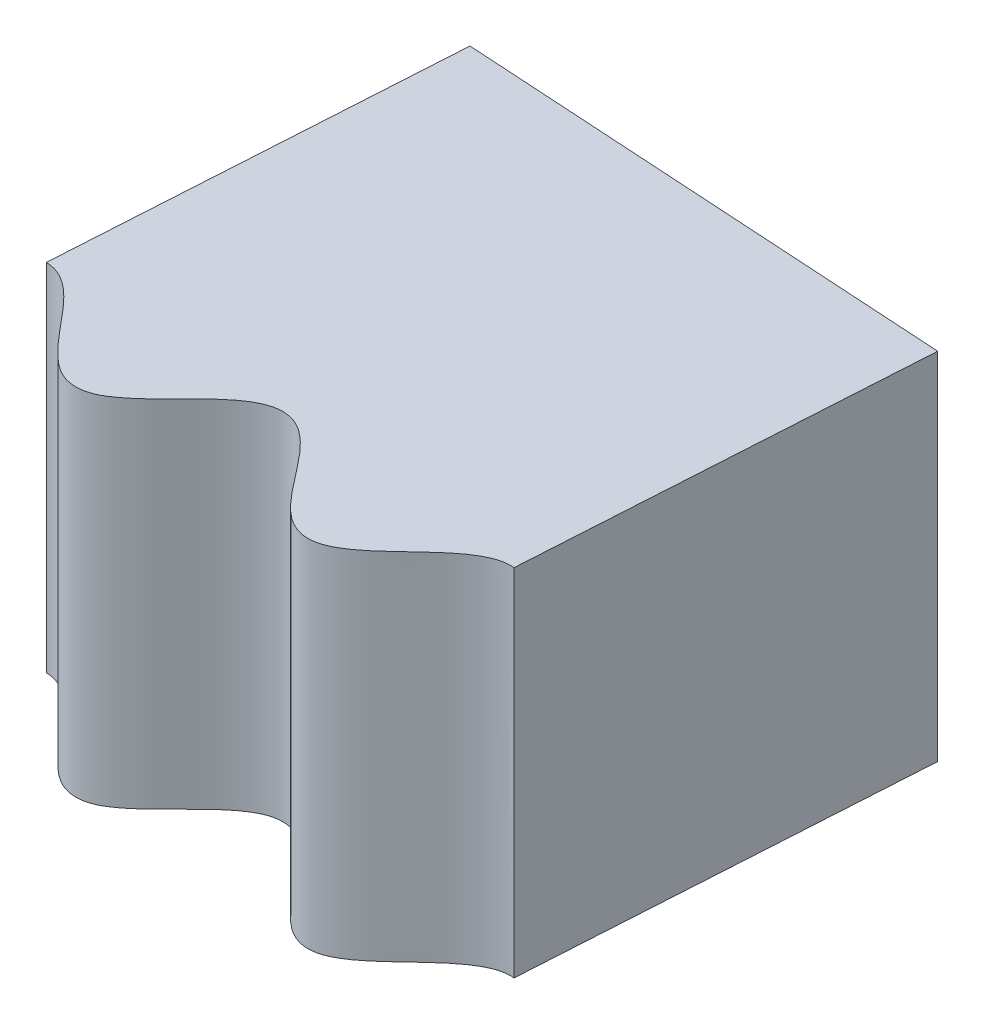
from build123d import *

# Parameters (mm, degrees)
BOSS_EXTRUDE1_DEPTH     = 4
CUT_EXTRUDE2_DEPTH      = 121.274685761
CUT_EXTRUDE2_DEPTH_BACK = 121.274685761
CUT_EXTRUDE1_DEPTH      = 121.251093253
CUT_EXTRUDE1_DEPTH_BACK = 121.251093253
CUT_EXTRUDE3_DEPTH      = 86.435194315
CUT_EXTRUDE3_DEPTH_BACK = 86.435194315


with BuildPart() as part:
    # Sketch1 → Boss-Extrude1 (new body)
    with BuildSketch(Plane(origin=(0, 0, 0), x_dir=(1, 0, 0), z_dir=(0, 1, 0))):
        with BuildLine():
            Line((0, 80), (0, 85))
            ThreePointArc((0, 85), (60.104076401, 60.104076401), (85, 0))
            Line((85, 0), (80, 0))
            add(Edge.make_bspline(
                [(80, 0), (80.032090717, 0.028525082), (80.09667822, 0.086017331), (80.241929685, 0.217881601), (80.358059175, 0.349965911), (80.491818845, 0.541955952), (80.520745314, 0.783221767), (80.395327209, 1.015001531), (80.21322013, 1.199882887), (80.019631559, 1.371789898), (79.826748629, 1.530214422), (79.652000677, 1.70136719), (79.499388097, 1.886384289), (79.436617102, 2.157129349), (79.580228142, 2.421089692), (79.756663775, 2.606493625), (79.935468278, 2.777108248), (80.081231654, 2.915952271), (80.195849331, 3.032747038), (80.318945031, 3.184834192), (80.449207906, 3.391122788), (80.430985375, 3.64769414), (80.283129745, 3.837080355), (80.117832534, 4.004725139), (79.930022356, 4.155872665), (79.708375258, 4.329496591), (79.496329517, 4.518081178), (79.348442966, 4.734680192), (79.342274426, 4.961075155), (79.417139165, 5.131209739), (79.541145524, 5.302751999), (79.700661546, 5.478726151), (79.895818296, 5.665940565), (80.087266659, 5.883785833), (80.264900479, 6.127148528), (80.26976254, 6.439577112), (80.0755926, 6.668708746), (79.870536592, 6.84659362), (79.650975963, 7.00393118), (79.449988691, 7.155400956), (79.27401932, 7.316136075), (79.133629081, 7.503746818), (79.112665659, 7.768606839), (79.258587358, 8.017453494), (79.445412966, 8.24075344), (79.677556155, 8.482920187), (79.871420236, 8.718646235), (80.039596562, 9.019993428), (79.92941115, 9.346326353), (79.684651627, 9.547767873), (79.43513913, 9.732924875), (79.168139401, 9.907991918), (78.948472427, 10.088325954), (78.798706362, 10.315149052), (78.818197293, 10.555217344), (78.907498739, 10.733000974), (79.031571912, 10.909532487), (79.179071405, 11.085986895), (79.343006349, 11.272289095), (79.500190837, 11.48122682), (79.627415603, 11.704481342), (79.633691009, 11.961120851), (79.497215431, 12.15943856), (79.333489111, 12.302792108), (79.151724532, 12.428199271), (78.96735588, 12.545156022), (78.781957065, 12.663685776), (78.608128462, 12.796358014), (78.448949239, 12.957441509), (78.373672933, 13.186175672), (78.44663846, 13.417225876), (78.569172307, 13.615068933), (78.712974029, 13.803259394), (78.859737418, 13.984594552), (79.002279528, 14.174046118), (79.121513223, 14.373582722), (79.192049351, 14.616633976), (79.096415003, 14.86130363), (78.903467998, 15.028975991), (78.691277914, 15.172659445), (78.479735827, 15.293184025), (78.285251138, 15.410267973), (78.111351638, 15.534657737), (77.967813395, 15.671478127), (77.865884414, 15.886642463), (77.923041339, 16.149590225), (78.071503052, 16.388213081), (78.255696078, 16.639452654), (78.420932264, 16.860272656), (78.544873375, 17.07058574), (78.610556053, 17.271422439), (78.602249155, 17.452728269), (78.491816209, 17.645978489), (78.286096374, 17.809888636), (78.026536396, 17.955157584), (77.723668771, 18.11800232), (77.462777072, 18.277975), (77.276991592, 18.510420725), (77.289695754, 18.771670067), (77.375412583, 18.967131426), (77.491230255, 19.162148753), (77.62406371, 19.35464712), (77.766439251, 19.559540843), (77.890938798, 19.77975678), (77.982928534, 20.031857992), (77.908617702, 20.297849989), (77.703954888, 20.469361632), (77.487293574, 20.600952596), (77.263484027, 20.710373317), (77.05385777, 20.814877214), (76.859115823, 20.930266104), (76.690132494, 21.062003172), (76.560195053, 21.288945194), (76.617887744, 21.580128607), (76.768630472, 21.845533697), (76.955776817, 22.134761377), (77.110836158, 22.388081211), (77.209207274, 22.632836471), (77.205193549, 22.855709333), (77.119274234, 23.015399798), (76.962130826, 23.156168852), (76.751178763, 23.278597763), (76.499083101, 23.390850954), (76.21708721, 23.52206724), (75.971563576, 23.660183858), (75.799525977, 23.867867226), (75.792450997, 24.105862415), (75.853791353, 24.293834195), (75.947079263, 24.486611265), (76.060800958, 24.682820779), (76.187126301, 24.891290148), (76.302107973, 25.119836012), (76.385056234, 25.358438422), (76.345683614, 25.608740652), (76.178082821, 25.779240722), (75.991835141, 25.892009555), (75.791119726, 25.983935286), (75.589210335, 26.067106475), (75.386060909, 26.151638253), (75.19182829, 26.252111207), (75.007098158, 26.383105764), (74.893244889, 26.595293611), (74.924981219, 26.835503821), (75.011297963, 27.051619068), (75.120236333, 27.26192135), (75.233281408, 27.46598684), (75.340760126, 27.677312377), (75.423533198, 27.89452229), (75.450792328, 28.146129517), (75.314124435, 28.370475361), (75.094992733, 28.502095505), (74.861075921, 28.606749663), (74.63181876, 28.688709306), (74.419957316, 28.770242574), (74.227099685, 28.862545246), (74.061983498, 28.972361874), (73.924240153, 29.166557598), (73.934868336, 29.435435788), (74.039638158, 29.696213533), (74.177405584, 29.975620996), (74.30178647, 30.221779208), (74.387324153, 30.450419312), (74.417134037, 30.659610527), (74.377469912, 30.836719437), (74.235157143, 31.007857271), (74.004099956, 31.133554381), (73.723257589, 31.23154425), (73.396713512, 31.339322597), (73.11200638, 31.451561565), (72.888679623, 31.648214607), (72.855825307, 31.907701039), (72.906298397, 32.115077472), (72.986492135, 32.327243575), (73.08388056, 32.539883747), (73.188513675, 32.766387927), (73.272881698, 33.004877409), (73.319696988, 33.269122487), (73.200326078, 33.518169527), (72.968989868, 33.651536198), (72.732769595, 33.743505157), (72.493359509, 33.812399412), (72.268771035, 33.878914442), (72.056950585, 33.958733732), (71.867658591, 34.059125771), (71.700287123, 34.260056633), (71.706539863, 34.556834546), (71.808905361, 34.844383737), (71.942984673, 35.16171502), (72.051699786, 35.438112129), (72.106075118, 35.696230972), (72.063420905, 35.915020918), (71.951076939, 36.057365594), (71.771876603, 36.168708383), (71.542869818, 36.252645883), (71.275111493, 36.319417743), (70.974614286, 36.399672486), (70.708837008, 36.493056071), (70.503349209, 36.667710246), (70.455054282, 36.900861195), (70.482821783, 37.096628904), (70.541217053, 37.302676532), (70.619139636, 37.515652748), (70.707345486, 37.742891163), (70.780893757, 37.987931262), (70.821148972, 38.237312577), (70.738909987, 38.476975175), (70.544248397, 38.615781384), (70.341248141, 38.694495455), (70.127619294, 38.750170714), (69.914334866, 38.797017253), (69.699592885, 38.844988062), (69.490864268, 38.910206862), (69.286193433, 39.007132581), (69.137224181, 39.196327638), (69.126765553, 39.438396934), (69.174244689, 39.666223619), (69.245005567, 39.892234757), (69.320905484, 40.112856767), (69.390040016, 40.339584176), (69.433863759, 40.567956834), (69.416975097, 40.820330666), (69.243496538, 41.017774742), (69.00470764, 41.108899633), (68.756436896, 41.172245697), (68.466910477, 41.219591467), (68.197666367, 41.278141747), (67.943151909, 41.357183881), (67.736316654, 41.559824915), (67.700319728, 41.827233163), (67.75804595, 42.101670586), (67.845317695, 42.401149899), (67.924993563, 42.664927635), (67.969563917, 42.905066899), (67.962580745, 43.116207209), (67.892770749, 43.283758824), (67.722899219, 43.427574017), (67.473527204, 43.511245532), (67.179934405, 43.558974547), (66.839636545, 43.608414404), (66.539764229, 43.669507867), (66.285682076, 43.824393739), (66.208267435, 44.074232523), (66.221963252, 44.287223227), (66.26409637, 44.510091413), (66.323080689, 44.736412497), (66.386792142, 44.977644882), (66.428465168, 45.227161545), (66.428683549, 45.495521527), (66.267879588, 45.720056447), (66.016899014, 45.811225864), (65.768297217, 45.86077839), (65.520560946, 45.88705286), (65.287834261, 45.913557999), (65.065371366, 45.955382419), (64.861522248, 46.021379067), (64.66180225, 46.190193588), (64.616425054, 46.483548555), (64.667302997, 46.784504809), (64.744241344, 47.120297745), (64.803308976, 47.411373942), (64.812036358, 47.675013557), (64.732037682, 47.883072766), (64.596682581, 48.003746581), (64.400870228, 48.082280012), (64.160766977, 48.125175701), (63.885481691, 48.144437402), (63.57561362, 48.171292103), (63.297658207, 48.217105241), (63.06496385, 48.353423445), (62.976916395, 48.574645982), (62.97026734, 48.772261314), (62.991995659, 48.985318849), (63.031751491, 49.208590592), (63.07915776, 49.447693531), (63.1090379, 49.701782441), (63.105376938, 49.954365341), (62.982770373, 50.176106271), (62.766962686, 50.279001081), (62.553377903, 50.321268662), (62.333326657, 50.339001879), (62.11514767, 50.348100153), (61.895338083, 50.358052845), (61.67845535, 50.386035069), (61.460063031, 50.445948262), (61.280503436, 50.606399505), (61.228169101, 50.842977732), (61.23536454, 51.075581698), (61.265805507, 51.310460321), (61.302238619, 51.540882841), (61.330957991, 51.77622379), (61.334449064, 52.008644375), (61.274009538, 52.254401043), (61.068852913, 52.418473933), (60.817919761, 52.467209091), (60.562315958, 52.485547277), (60.318852992, 52.484154182), (60.091882052, 52.488308333), (59.879086348, 52.509085605), (59.686367417, 52.5558024), (59.490513811, 52.691182513), (59.408536076, 52.947467163), (59.417803094, 53.228379739), (59.451686341, 53.538003137), (59.48439634, 53.811944809), (59.486542639, 54.055914862), (59.443062665, 54.262911016), (59.345103597, 54.415343831), (59.190928965, 54.506209058), (59.021409133, 54.546859543), (58.807638529, 54.565859484), (58.593895644, 54.563222757), (58.381584392, 54.55475325), (58.124257423, 54.557523545), (57.903842493, 54.575977162), (57.668244673, 54.669734184), (57.549220989, 54.901168507), (57.525372989, 55.113986964), (57.528372044, 55.340380655), (57.547048857, 55.573723864), (57.567961543, 55.822239621), (57.565644354, 56.075258871), (57.519272798, 56.339553105), (57.321914222, 56.532768248), (57.05892014, 56.578960596), (56.805487151, 56.584597543), (56.556953981, 56.567450078), (56.323159349, 56.553141981), (56.096813892, 56.555699812), (55.884601315, 56.585296164), (55.658601271, 56.716864817), (55.562972842, 56.997883513), (55.560817371, 57.303102343), (55.578276993, 57.647154089), (55.58590242, 57.944065138), (55.548716667, 58.205214985), (55.433804252, 58.396221677), (55.279550709, 58.491558022), (55.073075999, 58.534895893), (54.829171697, 58.535446409), (54.554723854, 58.506612692), (54.244900106, 58.479251385), (53.963212093, 58.476102067), (53.710381478, 58.569942341), (53.585256771, 58.77251473), (53.544393188, 58.965973245), (53.528794352, 59.17956704), (53.529175472, 59.406350311), (53.534341744, 59.650052751), (53.519645861, 59.905470112), (53.472179957, 60.153579991), (53.312931153, 60.350661771), (53.082534573, 60.414518766), (52.864854935, 60.4190556), (52.645067421, 60.398307911), (52.428623164, 60.369381578), (52.210424712, 60.341013532), (51.991977853, 60.330909353), (51.766499587, 60.351988902), (51.56180584, 60.478822333), (51.469185203, 60.702718643), (51.435880072, 60.933038307), (51.425072328, 61.169634614), (51.420939489, 61.402883042), (51.408356022, 61.6396357), (51.371434647, 61.869131511), (51.269238134, 62.100659372), (51.038707343, 62.226614549), (50.783123655, 62.231035232), (50.528218662, 62.204709672), (50.288696339, 62.161060868), (50.064452267, 62.125738764), (49.851281413, 62.109248902), (49.653378132, 62.12179049), (49.436991297, 62.221104565), (49.311755967, 62.459259785), (49.272101514, 62.73751516), (49.251705822, 63.048316025), (49.236347146, 63.323779964), (49.196099437, 63.564409949), (49.117329558, 63.760721738), (48.994401411, 63.893806335), (48.826762435, 63.956568769), (48.652821836, 63.967053399), (48.481411531, 63.95253118), (48.313051571, 63.924683497), (48.145760164, 63.89112429), (47.979054672, 63.856686781), (47.767363224, 63.821917449), (47.547153873, 63.801706918), (47.298824952, 63.853181073), (47.141436232, 64.06040471), (47.08098684, 64.265863314), (47.044632196, 64.489329977), (47.022503129, 64.72237584), (46.99994512, 64.970745182), (46.953726148, 65.219519286), (46.862165177, 65.471745417), (46.634253291, 65.62775453), (46.367233583, 65.627576472), (46.116671871, 65.589119738), (45.874892187, 65.529075371), (45.6471339, 65.474386676), (45.42378312, 65.437601152), (45.209654949, 65.429897551), (44.964242071, 65.520222877), (44.821267356, 65.780366575), (44.766145395, 66.080574134), (44.723593139, 66.422430823), (44.679549023, 66.716155218), (44.597573383, 66.966880449), (44.451249003, 67.135030872), (44.282763127, 67.202133233), (44.071948553, 67.208958193), (43.831535787, 67.167148153), (43.566501769, 67.091092419), (43.265745622, 67.0103509), (42.989451242, 66.958328371), (42.723403015, 67.0068481), (42.531623083, 67.223524481), (42.459146095, 67.478843201), (42.406452888, 67.749929216), (42.363518024, 68.039968415), (42.303789017, 68.288963767), (42.214408297, 68.525056842), (42.023119942, 68.691493925), (41.785273045, 68.714371273), (41.570029687, 68.681040452), (41.35723005, 68.622441743), (41.14907401, 68.556369978), (40.939127385, 68.490543019), (40.725749124, 68.442659499), (40.500037844, 68.424264891), (40.27642853, 68.513626752), (40.146336363, 68.718038162), (40.0735423, 68.939075383), (40.02181441, 69.17020051), (39.977241101, 69.399187719), (39.923737184, 69.63015846), (39.847525174, 69.849756412), (39.706676881, 70.060020561), (39.457776467, 70.14403102), (39.205308049, 70.104002757), (38.958846977, 70.033813665), (38.730543162, 69.949234732), (38.515839305, 69.875510927), (38.308770774, 69.822252381), (38.111695669, 69.800242159), (37.88135154, 69.860464998), (37.716661631, 70.073269306), (37.629295268, 70.340381392), (37.555231584, 70.642975121), (37.492285422, 70.911493744), (37.410844062, 71.141624788), (37.299214237, 71.32103598), (37.154986342, 71.431213668), (36.935963157, 71.470835971), (36.678166538, 71.418604846), (36.400042129, 71.313147447), (36.080616268, 71.185811964), (35.790372133, 71.088785785), (35.492887773, 71.095879082), (35.300925244, 71.273538875), (35.206290872, 71.464841915), (35.131345097, 71.678918121), (35.069266491, 71.904410015), (35.003826028, 72.145179155), (34.915157597, 72.382103417), (34.781166731, 72.614619178), (34.529638952, 72.728670137), (34.266698699, 72.682134886), (34.026626946, 72.600747729), (33.798943844, 72.499633959), (33.584143983, 72.406224728), (33.370573385, 72.331214312), (33.161036326, 72.286444492), (32.90366684, 72.332782216), (32.717690853, 72.564146358), (32.611275751, 72.850221323), (32.510007216, 73.179495283), (32.415627492, 73.461109179), (32.291359286, 73.693790414), (32.118058874, 73.833977272), (31.940480493, 73.870802981), (31.731683486, 73.840916569), (31.502183458, 73.757994769), (31.254382661, 73.637071233), (30.97221659, 73.505331565), (30.709152931, 73.406119968), (30.438721781, 73.407705635), (30.212229022, 73.587784936), (30.096519567, 73.826646036), (29.997549177, 74.084450185), (29.904908502, 74.362649209), (29.802837921, 74.597452886), (29.673836044, 74.814497117), (29.456524224, 74.945097584), (29.218370619, 74.926496163), (29.01206448, 74.855903152), (28.763118785, 74.738529977), (28.522990551, 74.607093087), (28.275755591, 74.488415411), (28.003061301, 74.417695808), (27.76723664, 74.466562248), (27.603684062, 74.645469155), (27.493577147, 74.850390665), (27.402520796, 75.069087435), (27.318851046, 75.28682196), (27.226057413, 75.505009403), (27.112868166, 75.708029671), (26.937648658, 75.890644537), (26.677940829, 75.930155929), (26.436259135, 75.846896167), (26.205730352, 75.734975187), (25.995582087, 75.612037062), (25.796942005, 75.502150149), (25.602267587, 75.413743734), (25.412008521, 75.357846132), (25.174706255, 75.377155227), (24.975565273, 75.558128448), (24.843142676, 75.806011498), (24.717659335, 76.09114712), (24.609041698, 76.344655858), (24.488875778, 76.557148549), (24.347787435, 76.714449767), (24.186618531, 76.797908697), (23.964042459, 76.798896071), (23.719232189, 76.702692541), (23.463645601, 76.55054148), (23.17118411, 76.369672791), (22.902197856, 76.223720292), (22.608001214, 76.179048209), (22.388104727, 76.320675007), (22.26168864, 76.492638639), (22.150707517, 76.690448348), (22.050415767, 76.901734677), (21.94416037, 77.127482375), (21.815697545, 77.345410114), (21.643366363, 77.551126169), (21.375855115, 77.619767097), (21.124990277, 77.528279725), (20.902698485, 77.406440999), (20.696032623, 77.267326619), (20.500716397, 77.13803688), (20.303415839, 77.027079896), (20.104836316, 76.946604501), (19.84333039, 76.947546508), (19.620003833, 77.143101318), (19.46552902, 77.406351373), (19.308621159, 77.713037825), (19.166773535, 77.973984506), (19.003988569, 78.181551843), (18.808977788, 78.289515647), (18.627702504, 78.294945729), (18.427267314, 78.229256138), (18.215653126, 78.107741846), (17.992615131, 77.945625253), (17.737612151, 77.766889383), (17.495772932, 77.623504507), (17.229174892, 77.578106208), (16.974852624, 77.716119645), (16.819423261, 77.931259172), (16.677189234, 78.167960668), (16.537647223, 78.425846342), (16.396354096, 78.639358448), (16.231622708, 78.830704356), (15.994933815, 78.921584896), (15.763628392, 78.861911154), (15.572714877, 78.756565877), (15.347932812, 78.597747007), (15.134276544, 78.426608894), (14.911405636, 78.266802645), (14.655134737, 78.1498041), (14.414406846, 78.156978398), (14.222272931, 78.30476504), (14.078252657, 78.487457424), (13.950607519, 78.687011201), (13.830391246, 78.886926472), (13.701135701, 79.085651831), (13.554383668, 79.265991417), (13.350805371, 79.414840666), (13.089946535, 79.409502692), (12.867823684, 79.287686387), (12.662361891, 79.139623902), (12.477922272, 78.983530443), (12.302331185, 78.840936938), (12.126075106, 78.718779355), (11.948231255, 78.628348143), (11.710874591, 78.601363226), (11.481266087, 78.741321619), (11.307642313, 78.960901779), (11.135331487, 79.217259747), (10.986111137, 79.446672282), (10.833685772, 79.634496951), (10.672126315, 79.767410528), (10.50363446, 79.828766417), (10.326851571, 79.808163944), (10.169170377, 79.734411639), (9.991585992, 79.614169208), (9.828515081, 79.475038744), (9.671136738, 79.332254519), (9.472861506, 79.166895561), (9.296023343, 79.040291377), (9.067666503, 78.952019938), (8.831116508, 79.026866307), (8.676729194, 79.158120569), (8.533439751, 79.324013421), (8.39492399, 79.513660989), (8.249637411, 79.724732238), (8.079461058, 79.930928358), (7.879504238, 80.115353271), (7.610438989, 80.159252516), (7.381037018, 80.045367942), (7.194599763, 79.904197349), (7.022727979, 79.743660945), (6.860646017, 79.588746957), (6.692993614, 79.43829234), (6.519600219, 79.314651913), (6.290756623, 79.220322946), (6.028482186, 79.293883819), (5.831281359, 79.490387514), (5.646452645, 79.713624779), (5.489117321, 79.928506877), (5.335395742, 80.110810396), (5.179541998, 80.254510164), (5.015916121, 80.34899745), (4.788976364, 80.365465627), (4.557164448, 80.243178952), (4.375950865, 80.081635606), (4.206759725, 79.910837233), (4.067666468, 79.76947905), (3.95277447, 79.657492058), (3.803176959, 79.538356281), (3.606111769, 79.404845332), (3.310544383, 79.411562322), (3.100666002, 79.602337005), (2.941849536, 79.767466049), (2.792005794, 79.952903647), (2.635102857, 80.139579158), (2.45731758, 80.335675828), (2.165797678, 80.527379943), (1.833803496, 80.427744539), (1.608206808, 80.212011435), (1.391907736, 79.987672297), (1.185105816, 79.754341161), (0.965353094, 79.560303773), (0.690983831, 79.449463641), (0.422747707, 79.573874153), (0.265392373, 79.707864443), (0.102037542, 79.885175448), (0.034337284, 79.961370556), (0, 80)],
                knots=[0.078729497, 0.078729497, 0.078729497, 0.078729497, 0.078729497, 0.079810127, 0.080890758, 0.081971388, 0.083052018, 0.084446577, 0.085841135, 0.087235694, 0.088630252, 0.089890942, 0.091151631, 0.092412321, 0.093673011, 0.095393984, 0.097114958, 0.097975445, 0.098835931, 0.099696418, 0.100556905, 0.102183376, 0.103809848, 0.10465964, 0.105509433, 0.107209018, 0.108908603, 0.110608189, 0.11157507, 0.112541952, 0.113508834, 0.114475715, 0.116040739, 0.117605764, 0.119170788, 0.120735812, 0.122215246, 0.123694679, 0.125174112, 0.126653546, 0.127852818, 0.12905209, 0.130251363, 0.131450635, 0.133170383, 0.134890131, 0.136609879, 0.138329627, 0.139960295, 0.141590962, 0.143266615, 0.144942267, 0.14661792, 0.148293572, 0.14934542, 0.150397267, 0.151449114, 0.152500962, 0.153895488, 0.155290014, 0.15668454, 0.158079067, 0.159241311, 0.160403555, 0.161565799, 0.162728043, 0.163890287, 0.165052532, 0.166214776, 0.16737702, 0.168622267, 0.169867515, 0.171112762, 0.172358009, 0.173603256, 0.174848504, 0.176093751, 0.177338998, 0.178703351, 0.180067703, 0.181432055, 0.182796408, 0.183845339, 0.18489427, 0.185943201, 0.186992131, 0.188637123, 0.190282115, 0.191927107, 0.193572099, 0.19450032, 0.195428542, 0.196356764, 0.197284985, 0.199093402, 0.200901818, 0.202710235, 0.204518651, 0.205654246, 0.206789841, 0.207925436, 0.209061031, 0.210424843, 0.211788656, 0.213152468, 0.21451628, 0.215880181, 0.217244082, 0.218607982, 0.219971883, 0.221107286, 0.222242688, 0.223378091, 0.224513494, 0.226322086, 0.228130678, 0.22993927, 0.231747861, 0.232676136, 0.23360441, 0.234532684, 0.235460959, 0.23710545, 0.238749941, 0.240394432, 0.242038922, 0.243088353, 0.244137784, 0.245187215, 0.246236646, 0.247600875, 0.248965105, 0.250329335, 0.251693564, 0.252855809, 0.254018053, 0.255180297, 0.256342541, 0.257504785, 0.258667029, 0.259829274, 0.260991518, 0.262236765, 0.263482012, 0.26472726, 0.265972507, 0.267217754, 0.268463002, 0.269708249, 0.270953496, 0.272317849, 0.273682201, 0.275046553, 0.276410906, 0.277459836, 0.278508767, 0.279557698, 0.280606629, 0.282251621, 0.283896613, 0.285541605, 0.287186597, 0.288114818, 0.28904304, 0.289971262, 0.290899483, 0.2927079, 0.294516316, 0.296324732, 0.298133149, 0.299268744, 0.300404339, 0.301539934, 0.302675529, 0.304039341, 0.305403153, 0.306766966, 0.308130778, 0.309494679, 0.310858579, 0.31222248, 0.313586381, 0.314721784, 0.315857186, 0.316992589, 0.318127992, 0.319936584, 0.321745176, 0.323553767, 0.325362359, 0.326290634, 0.327218908, 0.328147182, 0.329075457, 0.330719947, 0.332364438, 0.334008929, 0.33565342, 0.336702851, 0.337752282, 0.338801713, 0.339851143, 0.341215373, 0.342579603, 0.343943833, 0.345308062, 0.346470306, 0.347632551, 0.348794795, 0.349957039, 0.351119283, 0.352281527, 0.353443771, 0.354606016, 0.355851263, 0.35709651, 0.358341758, 0.359587005, 0.360832252, 0.362077499, 0.363322747, 0.364567994, 0.365932346, 0.367296699, 0.368661051, 0.370025403, 0.372123265, 0.373172196, 0.374221127, 0.375866119, 0.377511111, 0.379156103, 0.380801094, 0.381729316, 0.382657538, 0.383585759, 0.384513981, 0.386322397, 0.388130814, 0.38993923, 0.391747646, 0.392883242, 0.394018837, 0.395154432, 0.396290027, 0.397653839, 0.399017651, 0.400381464, 0.401745276, 0.403109177, 0.404473077, 0.405836978, 0.407200879, 0.408336281, 0.409471684, 0.410607087, 0.41174249, 0.413551081, 0.415359673, 0.417168265, 0.418976857, 0.419905131, 0.420833406, 0.42176168, 0.422689954, 0.424334445, 0.425978936, 0.427623427, 0.429267918, 0.430317349, 0.43136678, 0.43241621, 0.433465641, 0.434829871, 0.436194101, 0.43755833, 0.43892256, 0.440084804, 0.441247048, 0.442409293, 0.443571537, 0.444733781, 0.445896025, 0.447058269, 0.448220513, 0.449465761, 0.450711008, 0.451956255, 0.453201503, 0.45444675, 0.455691997, 0.456937245, 0.458182492, 0.459546844, 0.460911196, 0.462275549, 0.463639901, 0.464688832, 0.465737763, 0.466786694, 0.467835625, 0.469480617, 0.471125609, 0.4727706, 0.474415592, 0.475343814, 0.476272036, 0.477200257, 0.478128479, 0.479032687, 0.479936895, 0.481745312, 0.48264952, 0.483553728, 0.485362144, 0.486497739, 0.487633334, 0.488768929, 0.489904524, 0.491268337, 0.492632149, 0.493995961, 0.495359774, 0.496723674, 0.498087575, 0.499451476, 0.500815376, 0.501950779, 0.503086182, 0.504221585, 0.505356987, 0.507165579, 0.508974171, 0.510782763, 0.512591355, 0.513519629, 0.514447903, 0.515376178, 0.516304452, 0.517948943, 0.519593434, 0.521237925, 0.522882416, 0.523931847, 0.524981277, 0.526030708, 0.527080139, 0.528444369, 0.529808598, 0.531172828, 0.532537058, 0.533699302, 0.534861546, 0.53602379, 0.537186035, 0.538348279, 0.539510523, 0.540672767, 0.541835011, 0.543080259, 0.544325506, 0.545570753, 0.546816, 0.548061248, 0.549306495, 0.550551742, 0.55179699, 0.553161342, 0.554525694, 0.555890047, 0.557254399, 0.55830333, 0.559352261, 0.560401192, 0.561450123, 0.563095115, 0.564740106, 0.566385098, 0.56803009, 0.568958312, 0.569886533, 0.570814755, 0.571742977, 0.572647185, 0.573551393, 0.574455601, 0.575359809, 0.576264018, 0.577168226, 0.578976642, 0.580112237, 0.581247832, 0.582383427, 0.583519022, 0.584882835, 0.586246647, 0.587610459, 0.588974272, 0.590338172, 0.591702073, 0.593065974, 0.594429874, 0.595565277, 0.59670068, 0.597836082, 0.598971485, 0.600780077, 0.602588669, 0.604397261, 0.606205853, 0.607134127, 0.608062401, 0.608990676, 0.60991895, 0.611563441, 0.613207932, 0.614852423, 0.616496914, 0.617546344, 0.618595775, 0.620694637, 0.622058867, 0.623423096, 0.624787326, 0.626151556, 0.6273138, 0.628476044, 0.629638288, 0.630800532, 0.631962777, 0.633125021, 0.634287265, 0.635449509, 0.636694756, 0.637940004, 0.639185251, 0.640430498, 0.641675746, 0.642920993, 0.64416624, 0.645411487, 0.64677584, 0.648140192, 0.649504544, 0.650868897, 0.651917828, 0.652966759, 0.65401569, 0.655064621, 0.656709612, 0.658354604, 0.659999596, 0.661644588, 0.662572809, 0.663501031, 0.664429253, 0.665357474, 0.667165891, 0.668974307, 0.670782724, 0.67259114, 0.673726735, 0.67486233, 0.675997925, 0.67713352, 0.678497332, 0.679861145, 0.681224957, 0.682588769, 0.68395267, 0.685316571, 0.686680471, 0.688044372, 0.689179775, 0.690315178, 0.69145058, 0.692585983, 0.694394575, 0.696203167, 0.698011759, 0.69982035, 0.700748625, 0.701676899, 0.702605173, 0.703533448, 0.705177939, 0.70682243, 0.708466921, 0.710111411, 0.711160842, 0.712210273, 0.714309135, 0.715673364, 0.717037594, 0.718401824, 0.719766053, 0.720928298, 0.722090542, 0.723252786, 0.72441503, 0.726739519, 0.727901763, 0.729064007, 0.730309254, 0.731554501, 0.732799749, 0.734044996, 0.735290243, 0.736535491, 0.737780738, 0.739025985, 0.740390338, 0.74175469, 0.743119042, 0.744483395, 0.745532326, 0.746581256, 0.747630187, 0.748679118, 0.75032411, 0.751969102, 0.753614094, 0.755259086, 0.756187307, 0.757115529, 0.758043751, 0.758971972, 0.760780389, 0.762588805, 0.764397221, 0.766205638, 0.767341233, 0.768476828, 0.769612423, 0.770748018, 0.77211183, 0.773475643, 0.774839455, 0.776203267, 0.777567168, 0.778931069, 0.780294969, 0.78165887, 0.782794273, 0.783929675, 0.785065078, 0.786200481, 0.788009073, 0.789817665, 0.791626256, 0.793434848, 0.794363123, 0.795291397, 0.796219671, 0.797147946, 0.798792437, 0.800436927, 0.802081418, 0.803725909, 0.80477534, 0.805824771, 0.807923632, 0.809287862, 0.810652092, 0.812016322, 0.813380551, 0.814542795, 0.81570504, 0.816867284, 0.818029528, 0.820354016, 0.82151626, 0.822678505, 0.823923752, 0.825168999, 0.826414247, 0.827659494, 0.828904741, 0.830149988, 0.831395236, 0.832640483, 0.83398875, 0.835337016, 0.836685283, 0.83803355, 0.839091115, 0.84014868, 0.841206246, 0.842263811, 0.843895715, 0.845527619, 0.847159523, 0.848791427, 0.849711374, 0.850631321, 0.851551268, 0.852471215, 0.853376911, 0.854282606, 0.856093997, 0.856999692, 0.857905387, 0.859716778, 0.860781232, 0.861845687, 0.862910141, 0.863974595, 0.865412579, 0.866850562, 0.868288545, 0.869726529, 0.870984386, 0.872242243, 0.873500101, 0.874757958, 0.875906438, 0.877054919, 0.878203399, 0.879351879, 0.88089951, 0.882447141, 0.883994772, 0.885542403, 0.886521803, 0.887501203, 0.888480603, 0.889460003, 0.891148191, 0.892836378, 0.893680472, 0.894524566, 0.895368659, 0.896212753, 0.897801222, 0.899389691, 0.901075191, 0.901917941, 0.902760691, 0.90444619, 0.90613169, 0.907802714, 0.909473738, 0.911119647, 0.912765555, 0.914411464, 0.916057373, 0.917358189, 0.918659006, 0.919959823, 0.92126064, 0.92126064, 0.92126064, 0.92126064, 0.92126064], degree=4))
        make_face()
    extrude(amount=BOSS_EXTRUDE1_DEPTH)

    # Sketch3 → Cut-Extrude2 (cut, two sides)
    with BuildSketch(Plane(origin=(0, 4, 0), x_dir=(1, 0, 0), z_dir=(0, 1, 0))) as cut_extrude2_sk:
        with BuildLine():
            add(Edge.make_bspline(
                [(2.107227957, 80.47178907), (2.080770093, 80.472249765), (1.976130955, 80.465025662), (1.796326998, 80.391906595), (1.608206808, 80.212011435), (1.391907736, 79.987672297), (1.185105816, 79.754341161), (0.965353094, 79.560303773), (0.690983831, 79.449463641), (0.422747707, 79.573874153), (0.265392373, 79.707864443), (0.102037542, 79.885175448), (0.034337284, 79.961370556), (0, 80)],
                knots=[0.907233719, 0.907233719, 0.907233719, 0.907233719, 0.907233719, 0.907802714, 0.909473738, 0.911119647, 0.912765555, 0.914411464, 0.916057373, 0.917358189, 0.918659006, 0.919959823, 0.92126064, 0.92126064, 0.92126064, 0.92126064, 0.92126064], degree=4))
            Line((2.107227957, 80.47178907), (2.382143191, 84.966613407))
            ThreePointArc((2.382143191, 84.966613407), (1.191188571, 84.991652942), (0, 85))
            Line((0, 85), (0, 80.000000001))
        make_face()
    extrude(amount=CUT_EXTRUDE2_DEPTH, mode=Mode.SUBTRACT)
    extrude(cut_extrude2_sk.sketch, amount=-CUT_EXTRUDE2_DEPTH_BACK, mode=Mode.SUBTRACT)

    # Sketch2 → Cut-Extrude1 (cut, two sides)
    with BuildSketch(Plane(origin=(0, 4, 0), x_dir=(1, 0, 0), z_dir=(0, 1, 0))) as cut_extrude1_sk:
        with BuildLine():
            Line((84.999999996, -247.407136243), (85, -1e-09))
            ThreePointArc((85, -1e-09), (62.865677354, 57.209322762), (7.990432685, 84.623595915))
            Line((7.990432685, 84.623595915), (7.71550753, 80.128609378))
            Line((7.71550753, 80.128609378), (-7.388336825, -166.817062682))
            Line((-7.388336825, -166.817062682), (-332.654592548, -539.701799752))
            Line((-332.654592548, -539.701799752), (-240.266255728, -620.291873313))
            Line((-240.266255728, -620.291873313), (84.999999996, -247.407136243))
        make_face()
    extrude(amount=CUT_EXTRUDE1_DEPTH, mode=Mode.SUBTRACT)
    extrude(cut_extrude1_sk.sketch, amount=-CUT_EXTRUDE1_DEPTH_BACK, mode=Mode.SUBTRACT)

    # Sketch4 → Cut-Extrude3 (cut, two sides)
    with BuildSketch(Plane(origin=(0, 4, 0), x_dir=(1, 0, 0), z_dir=(0, 1, 0))) as cut_extrude3_sk:
        with BuildLine():
            Line((2.382143191, 84.966613407), (7.990432685, 84.623595915))
            ThreePointArc((7.990432685, 84.623595915), (5.18912303, 84.841458039), (2.382143191, 84.966613407))
        make_face()
    extrude(amount=CUT_EXTRUDE3_DEPTH, mode=Mode.SUBTRACT)
    extrude(cut_extrude3_sk.sketch, amount=-CUT_EXTRUDE3_DEPTH_BACK, mode=Mode.SUBTRACT)


solid = part.part
